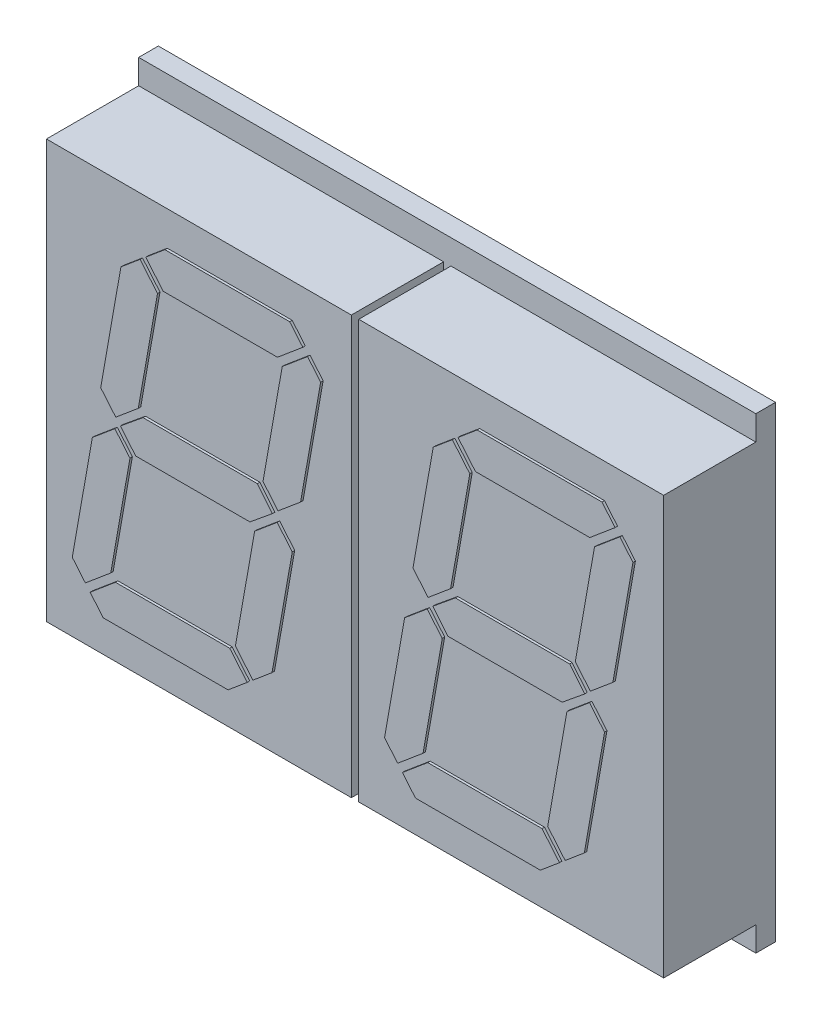
from build123d import *

# Parameters (mm, degrees)
SKETCH_1_W      = 25.1
SKETCH_1_H      = 19
EXTRUDE_1_DEPTH = 0.8
SKETCH_2_W      = 12.4
SKETCH_2_H      = 17
EXTRUDE_2_DEPTH = 3.75
EXTRUDE_3_DEPTH = 0.1


with BuildPart() as part:
    # Эскиз1 → Бобышка-Вытянуть1 (new body)
    with BuildSketch(Plane.XY):
        Rectangle(SKETCH_1_W, SKETCH_1_H)
    extrude(amount=EXTRUDE_1_DEPTH)

    # Эскиз2 → Бобышка-Вытянуть2 (add)
    with BuildSketch(Plane.XY.offset(0.8)):
        with Locations((-6.35, 0)):
            Rectangle(SKETCH_2_W, SKETCH_2_H)
        with Locations((6.35, 0)):
            Rectangle(SKETCH_2_W, SKETCH_2_H)
    extrude(amount=EXTRUDE_2_DEPTH)

    # Эскиз3 → Бобышка-Вытянуть3 (add)
    with BuildSketch(Plane.XY.offset(4.55)):
        Polygon((-2.02468415, 6.47520488), (-2.557441739, 7.110113629), (-7.634747282, 7.110113629), (-8.413649878, 6.456542649), (-7.703502871, 5.610259577), (-3.055232199, 5.610259577), align=None)
        Polygon((-1.29882158, 5.610259577), (-2.115441527, 0.979668914), (-3.03146241, 0.211374323), (-3.644937808, 0.942733655), (-2.862323662, 5.380419467), (-1.831775613, 6.245561214), align=None)
        Polygon((-7.933342981, 5.41735104), (-8.715781578, 0.979668914), (-9.631802461, 0.211374323), (-10.245102311, 0.942933785), (-9.422392583, 5.610259577), (-8.643686432, 6.263830557), align=None)
        Polygon((-8.523069486, 0.750025248), (-3.874798814, 0.750025248), (-3.260537626, 0), (-4.176367833, -0.749828804), (-8.824808297, -0.749828804), (-9.438886615, 0), align=None)
        Polygon((-3.984111693, -0.979995723), (-3.06780465, -0.211374323), (-2.454394697, -0.942560314), (-3.277521077, -5.609847275), (-4.056117123, -6.263437667), (-4.766565605, -5.416832984), align=None)
        Polygon((-9.054648407, -0.942737341), (-9.668341145, -0.211177879), (-10.584362029, -0.979472469), (-11.400981975, -5.609866688), (-10.868224387, -6.244775436), (-9.837186085, -5.37955138), align=None)
        Polygon((-4.996497129, -5.609866688), (-9.644374912, -5.609866688), (-10.674989606, -6.475066276), (-10.142165372, -7.110113629), (-5.064859829, -7.110113629), (-4.286153678, -6.456346204), align=None)
        Polygon((10.67560373, 6.47520488), (10.142846141, 7.110113629), (5.065540598, 7.110113629), (4.286638002, 6.456542649), (4.996785009, 5.610259577), (9.64505568, 5.610259577), align=None)
        Polygon((11.4014663, 5.610259577), (10.584846353, 0.979668914), (9.66882547, 0.211374323), (9.055350072, 0.942733655), (9.837964217, 5.380419467), (10.868512267, 6.245561214), align=None)
        Polygon((4.766944899, 5.41735104), (3.984506302, 0.979668914), (3.068485419, 0.211374323), (2.455185569, 0.942933785), (3.277895297, 5.610259577), (4.056601448, 6.263830557), align=None)
        Polygon((4.177218394, 0.750025248), (8.825489066, 0.750025248), (9.439750254, 0), (8.523920047, -0.749828804), (3.875479583, -0.749828804), (3.261401265, 0), align=None)
        Polygon((8.716176187, -0.979995723), (9.63248323, -0.211374323), (10.245893183, -0.942560314), (9.422766803, -5.609847275), (8.644170756, -6.263437667), (7.933722275, -5.416832984), align=None)
        Polygon((3.645639473, -0.942737341), (3.031946734, -0.211177879), (2.115925851, -0.979472469), (1.299305904, -5.609866688), (1.832063493, -6.244775436), (2.863101795, -5.37955138), align=None)
        Polygon((7.70379075, -5.609866688), (3.055912968, -5.609866688), (2.025298274, -6.475066276), (2.558122507, -7.110113629), (7.635428051, -7.110113629), (8.414134202, -6.456346204), align=None)
    extrude(amount=EXTRUDE_3_DEPTH)


solid = part.part
